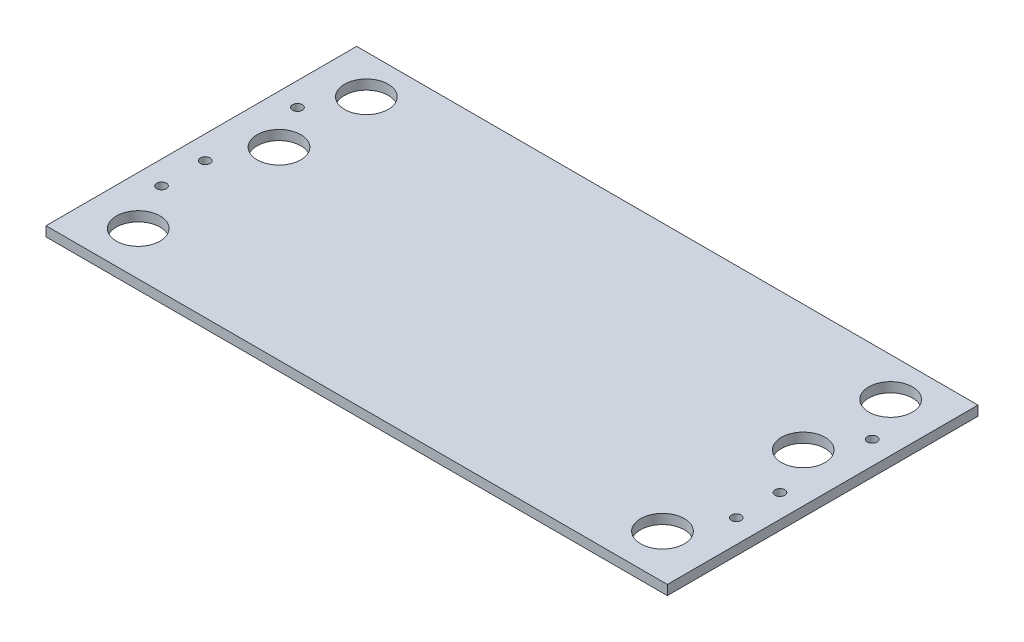
from build123d import *

# Parameters (mm, degrees)
SKETCH2_W           = 406.4
SKETCH2_H           = 203.2
SKETCH2_R           = 14.2875
SKETCH2_R_2         = 3.175
BOSS_EXTRUDE1_DEPTH = 6.35


with BuildPart() as part:
    # Sketch2 → Boss-Extrude1 (new body)
    with BuildSketch(Plane(origin=(0, 0, 0), x_dir=(1, 0, 0), z_dir=(0, 1, 0))):
        Rectangle(SKETCH2_W, SKETCH2_H)
        with Locations((-171.45, 76.2)):
            Circle(SKETCH2_R, mode=Mode.SUBTRACT)
        with Locations((-171.45, 19.05)):
            Circle(SKETCH2_R, mode=Mode.SUBTRACT)
        with Locations((171.45, 76.2)):
            Circle(SKETCH2_R, mode=Mode.SUBTRACT)
        with Locations((171.45, 19.05)):
            Circle(SKETCH2_R, mode=Mode.SUBTRACT)
        with Locations((171.45, -73.025)):
            Circle(SKETCH2_R, mode=Mode.SUBTRACT)
        with Locations((-171.45, -73.025)):
            Circle(SKETCH2_R, mode=Mode.SUBTRACT)
        with Locations((-187.96, -12.7)):
            Circle(SKETCH2_R_2, mode=Mode.SUBTRACT)
        with Locations((-187.96, -41.275)):
            Circle(SKETCH2_R_2, mode=Mode.SUBTRACT)
        with Locations((187.96, -41.275)):
            Circle(SKETCH2_R_2, mode=Mode.SUBTRACT)
        with Locations((187.96, -12.7)):
            Circle(SKETCH2_R_2, mode=Mode.SUBTRACT)
        with Locations((-187.96, 47.625)):
            Circle(SKETCH2_R_2, mode=Mode.SUBTRACT)
        with Locations((187.96, 47.625)):
            Circle(SKETCH2_R_2, mode=Mode.SUBTRACT)
    extrude(amount=BOSS_EXTRUDE1_DEPTH)


solid = part.part
